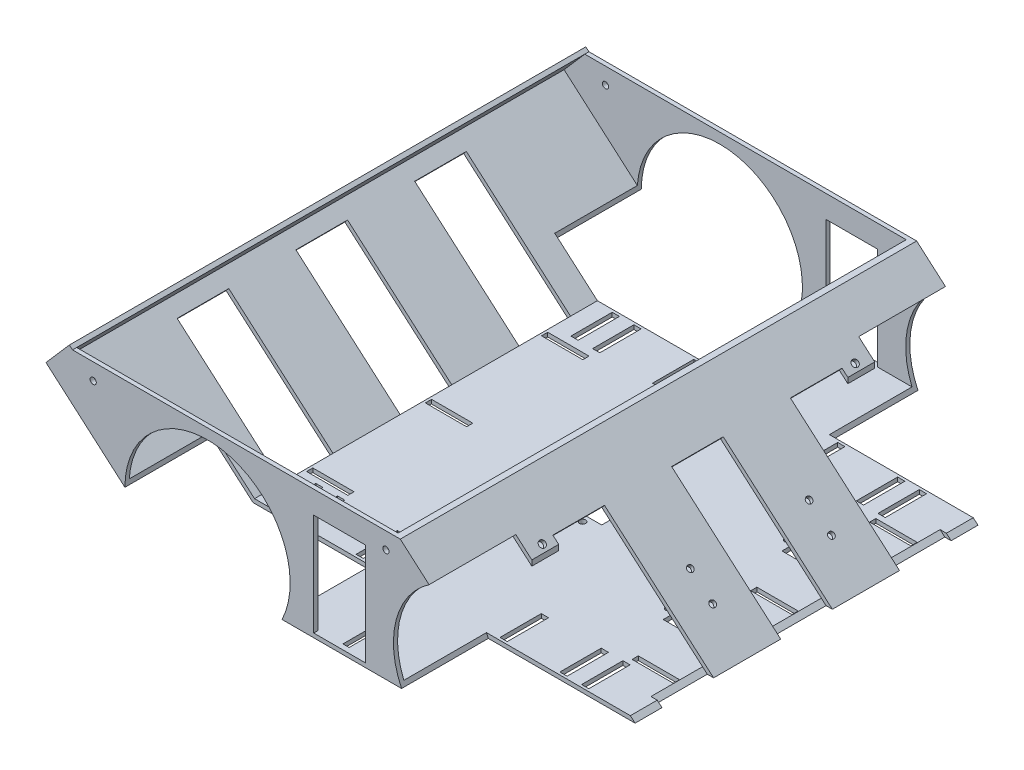
from build123d import *

# Parameters (mm, degrees)
EXTRUDE_1_DEPTH           = 250
SHELL_1_T                 = -2
SKETCH_4_R                = 40
CUT_EXTRUDE_3_DEPTH       = 42
SKETCH_6_R                = 40
CUT_EXTRUDE_5_DEPTH       = 42
SKETCH_7_R                = 1.5
SKETCH_7_W                = 3.5
SKETCH_7_H                = 20
SKETCH_7_W_2              = 12
SKETCH_7_W_3              = 20
SKETCH_7_H_2              = 12
CUT_EXTRUDE_6_DEPTH       = 32
SKETCH_8_W                = 50
SKETCH_8_H                = 50
CUT_EXTRUDE_7_DEPTH       = 15
SKETCH_9_W                = 50
SKETCH_9_H                = 48
CUT_EXTRUDE_8_DEPTH       = 15
SKETCH_10_W               = 70
SKETCH_10_H               = 25
CUT_EXTRUDE_9_DEPTH       = 2
SKETCH_13_W               = 25
SKETCH_13_H               = 49.428785774
CUT_EXTRUDE_10_DEPTH      = 304
SKETCH_14_W               = 66.85616243
SKETCH_14_H               = 25
CUT_EXTRUDE_11_DEPTH      = 2
SKETCH_15_W               = 3
SKETCH_15_H               = 20
SKETCH_15_W_2             = 20
SKETCH_15_H_2             = 3
CUT_EXTRUDE_12_DEPTH      = 2
SKETCH_16_R               = 1.5
CUT_EXTRUDE_13_DEPTH      = 90
SKETCH_18_R               = 1.6
CUT_EXTRUDE_14_DEPTH      = 5
CUT_EXTRUDE_15_DEPTH      = 264
SKETCH_20_W               = 250
SKETCH_20_H               = 17.277243338
EXTRUDE_2_DEPTH           = 2
SKETCH_21_R               = 1.5
CUT_EXTRUDE_17_DEPTH      = 1
CUT_EXTRUDE_17_DEPTH_BACK = 251


with BuildPart() as part:
    # 草图1 → 凸台-拉伸1 (new body)
    with BuildSketch(Plane.XY):
        Polygon((0, 0), (-185, 0), (-256.697410121, 62.325607754), (-71.697410121, 62.325607754), align=None)
    extrude(amount=EXTRUDE_1_DEPTH)

    # 抽壳1
    shell_1_openings = [part.faces().sort_by_distance(p)[0] for p in [
        (-164.197410121, 62.325607754, 125),
    ]]
    offset(amount=SHELL_1_T, openings=shell_1_openings, kind=Kind.INTERSECTION)

    # 草图4 → 切除-拉伸3 (cut)
    with BuildSketch(Plane.XY.offset(250)):
        with Locations((-35, 17.3)):
            Circle(SKETCH_4_R)
        with Locations((-165, 17.3)):
            Circle(SKETCH_4_R)
    extrude(amount=-CUT_EXTRUDE_3_DEPTH, mode=Mode.SUBTRACT)

    # 草图6 → 切除-拉伸5 (cut)
    with BuildSketch(Plane(origin=(0, 0, 0), x_dir=(-1, 0, 0), z_dir=(0, 0, -1))):
        with Locations((165, 17.3)):
            Circle(SKETCH_6_R)
        with BuildLine():
            ThreePointArc((15.18510716, -17.447230418), (75, 17.3), (15.18510716, 52.047230418))
            ThreePointArc((15.18510716, 52.047230418), (-45.184680822, 17.3), (15.18510716, -17.447230418))
        make_face()
    extrude(amount=-CUT_EXTRUDE_5_DEPTH, mode=Mode.SUBTRACT)

    # 草图7 → 切除-拉伸6 (cut)
    with BuildSketch(Plane(origin=(0, 2, 0), x_dir=(1, 0, 0), z_dir=(0, 1, 0))):
        with Locations((-95.174280419, -111.75)):
            Circle(SKETCH_7_R)
        with Locations((-95.174280419, -138.25)):
            Circle(SKETCH_7_R)
        with Locations((-11.41, -96.25)):
            Circle(SKETCH_7_R)
        with Locations((-37.91, -96.25)):
            Circle(SKETCH_7_R)
        with Locations((-37.91, -153.75)):
            Circle(SKETCH_7_R)
        with Locations((-11.41, -153.75)):
            Circle(SKETCH_7_R)
        with Locations((-174.09, -196.75)):
            Rectangle(SKETCH_7_W, SKETCH_7_H)
        with Locations((-25.41, -196.75)):
            Rectangle(SKETCH_7_W, SKETCH_7_H)
        with Locations((-163.59, -196.75)):
            Rectangle(SKETCH_7_W, SKETCH_7_H)
        with Locations((-134.59, -196.75)):
            Rectangle(SKETCH_7_W, SKETCH_7_H)
        with Locations((-35.91, -196.75)):
            Rectangle(SKETCH_7_W, SKETCH_7_H)
        with Locations((-64.91, -196.75)):
            Rectangle(SKETCH_7_W, SKETCH_7_H)
        with Locations((-134.59, -53.25)):
            Rectangle(SKETCH_7_W, SKETCH_7_H)
        with Locations((-163.59, -53.25)):
            Rectangle(SKETCH_7_W, SKETCH_7_H)
        with Locations((-174.09, -53.25)):
            Rectangle(SKETCH_7_W, SKETCH_7_H)
        with Locations((-64.91, -53.25)):
            Rectangle(SKETCH_7_W, SKETCH_7_H)
        with Locations((-35.91, -53.25)):
            Rectangle(SKETCH_7_W, SKETCH_7_H)
        with Locations((-25.41, -53.25)):
            Rectangle(SKETCH_7_W, SKETCH_7_H)
        with Locations((-95.174280419, -125)):
            Rectangle(SKETCH_7_W_2, SKETCH_7_H)
        with Locations((-24.66, -96.25)):
            Rectangle(SKETCH_7_W_3, SKETCH_7_H_2)
        with Locations((-24.66, -153.75)):
            Rectangle(SKETCH_7_W_3, SKETCH_7_H_2)
    extrude(amount=-CUT_EXTRUDE_6_DEPTH, mode=Mode.SUBTRACT)

    # 草图8 → 切除-拉伸7 (cut)
    with BuildSketch(Plane.XY.offset(208)):
        with Locations((-25, 27)):
            Rectangle(SKETCH_8_W, SKETCH_8_H)
    extrude(amount=-CUT_EXTRUDE_7_DEPTH, mode=Mode.SUBTRACT)

    # 草图9 → 切除-拉伸8 (cut)
    with BuildSketch(Plane(origin=(0, 0, 42), x_dir=(-1, 0, 0), z_dir=(0, 0, -1))):
        with Locations((25, 26)):
            Rectangle(SKETCH_9_W, SKETCH_9_H)
    extrude(amount=-CUT_EXTRUDE_8_DEPTH, mode=Mode.SUBTRACT)

    # 草图10 → 切除-拉伸9 (cut)
    with BuildSketch(Plane(origin=(0, 0, 0), x_dir=(0.75470958, -0.656059029, 0), z_dir=(0.656059029, 0.75470958, 0))):
        with Locations((-35, -182.5)):
            Rectangle(SKETCH_10_W, SKETCH_10_H)
        with Locations((-35, -67.5)):
            Rectangle(SKETCH_10_W, SKETCH_10_H)
        with Locations((-35, -125)):
            Rectangle(SKETCH_10_W, SKETCH_10_H)
    extrude(amount=-CUT_EXTRUDE_9_DEPTH, mode=Mode.SUBTRACT)

    # 草图13 → 切除-拉伸10 (cut)
    with BuildSketch(Plane(origin=(0, 0, 0), x_dir=(-1, 0, 0), z_dir=(0, 0, -1))):
        with Locations((101.10376969, 26.714392887)):
            Rectangle(SKETCH_13_W, SKETCH_13_H)
    extrude(amount=-CUT_EXTRUDE_10_DEPTH, mode=Mode.SUBTRACT)

    # 草图14 → 切除-拉伸11 (cut)
    with BuildSketch(Plane(origin=(-78.314370103, -90.090377198, 0), x_dir=(0.75470958, -0.656059029, 0), z_dir=(0.656059029, 0.75470958, 0))):
        with Locations((-173.797122915, -67.5)):
            Rectangle(SKETCH_14_W, SKETCH_14_H)
        with Locations((-173.797122915, -125)):
            Rectangle(SKETCH_14_W, SKETCH_14_H)
        with Locations((-173.797122915, -182.5)):
            Rectangle(SKETCH_14_W, SKETCH_14_H)
    extrude(amount=-CUT_EXTRUDE_11_DEPTH, mode=Mode.SUBTRACT)

    # 草图15 → 切除-拉伸12 (cut)
    with BuildSketch(Plane.XZ):
        with Locations((-100.462980788, 237.5)):
            Rectangle(SKETCH_15_W, SKETCH_15_H)
        with Locations((-15.456937779, 182.5)):
            Rectangle(SKETCH_15_W_2, SKETCH_15_H_2)
        with Locations((-15.548506173, 125)):
            Rectangle(SKETCH_15_W_2, SKETCH_15_H_2)
        with Locations((-15.548506173, 67.407755874)):
            Rectangle(SKETCH_15_W_2, SKETCH_15_H_2)
        with Locations((-100.787471441, 12.5)):
            Rectangle(SKETCH_15_W, SKETCH_15_H)
        with Locations((-173.064348699, 68.747523441)):
            Rectangle(SKETCH_15_W_2, SKETCH_15_H_2)
        with Locations((-173.064348699, 125)):
            Rectangle(SKETCH_15_W_2, SKETCH_15_H_2)
        with Locations((-173.064348699, 182.5)):
            Rectangle(SKETCH_15_W_2, SKETCH_15_H_2)
    extrude(amount=-CUT_EXTRUDE_12_DEPTH, mode=Mode.SUBTRACT)

    # 草图16 → 切除-拉伸13 (cut)
    with BuildSketch(Plane(origin=(-1.312118058, -1.50941916, 0), x_dir=(0.75470958, -0.656059029, 0), z_dir=(-0.656059029, -0.75470958, 0))):
        with Locations((-22.161189798, 96.25)):
            Circle(SKETCH_16_R)
        with Locations((-36.461189798, 96.25)):
            Circle(SKETCH_16_R)
        with Locations((-22.161189798, 153.75)):
            Circle(SKETCH_16_R)
        with Locations((-36.461189798, 153.75)):
            Circle(SKETCH_16_R)
    extrude(amount=-CUT_EXTRUDE_13_DEPTH, mode=Mode.SUBTRACT)

    # 草图18 → 切除-拉伸14 (cut)
    with BuildSketch(Plane(origin=(0, 0, 0), x_dir=(0.75470958, -0.656059029, 0), z_dir=(0.656059029, 0.75470958, 0))):
        with Locations((-69.177168292, -200.735802704)):
            Circle(SKETCH_18_R)
        with Locations((-69.177168292, -49.264197296)):
            Circle(SKETCH_18_R)
    extrude(amount=-CUT_EXTRUDE_14_DEPTH, mode=Mode.SUBTRACT)

    # 草图19 → 切除-拉伸15 (cut)
    with BuildSketch(Plane.XY.offset(250)):
        Polygon((-256.697410121, 62.325607754), (-241.697410121, 62.325607754), (-230.362518633, 62.325607754), (-241.697410121, 49.286306687), align=None)
    extrude(amount=-CUT_EXTRUDE_15_DEPTH, mode=Mode.SUBTRACT)

    # 草图20 → 凸台-拉伸2 (add)
    with BuildSketch(Plane(origin=(-162.07092196, 140.886103045, 0), x_dir=(0, 0, 1), z_dir=(-0.75470958, 0.656059029, 0))):
        with Locations((125, -112.732298694)):
            Rectangle(SKETCH_20_W, SKETCH_20_H)
    extrude(amount=EXTRUDE_2_DEPTH)

    # 草图21 → 切除-拉伸17 (cut, two sides)
    with BuildSketch(Plane.XY.offset(250)) as cut_extrude_17_sk:
        with Locations((-78.60376969, 54.325607754)):
            Circle(SKETCH_21_R)
        with Locations((-220.362518633, 54.325607754)):
            Circle(SKETCH_21_R)
    extrude(amount=CUT_EXTRUDE_17_DEPTH, mode=Mode.SUBTRACT)
    extrude(cut_extrude_17_sk.sketch, amount=-CUT_EXTRUDE_17_DEPTH_BACK, mode=Mode.SUBTRACT)


solid = part.part
